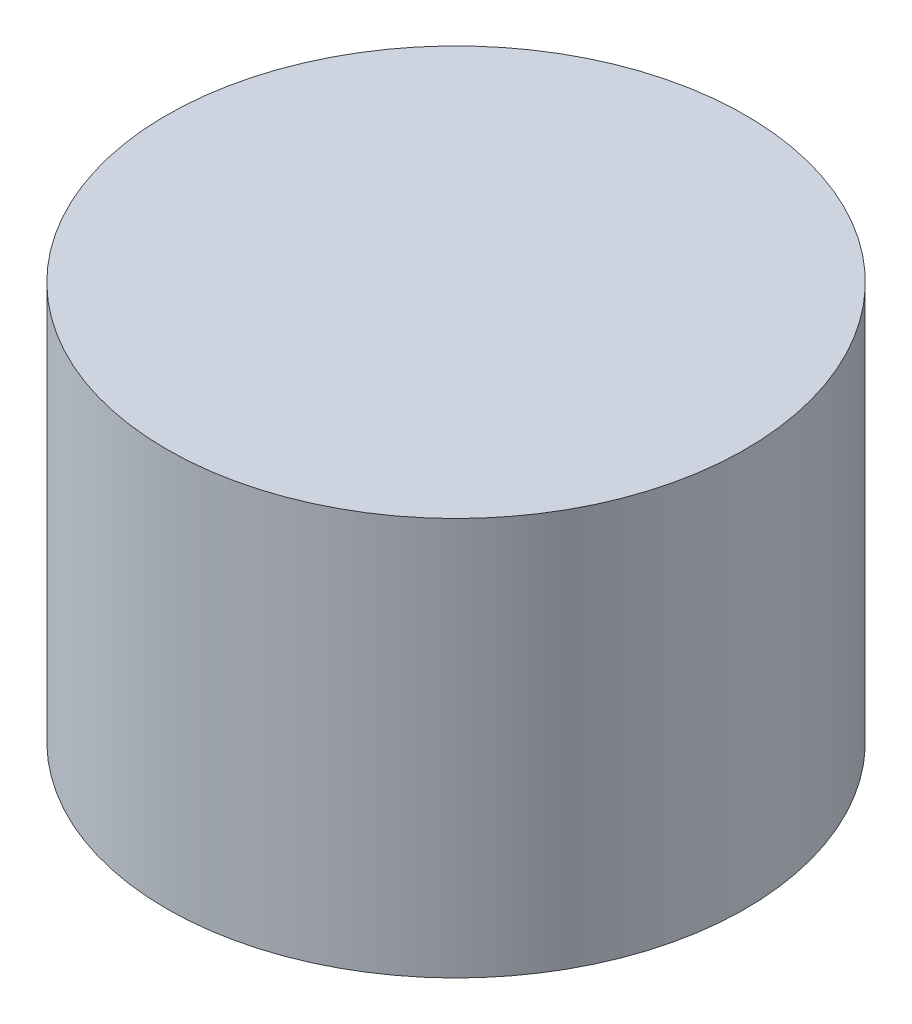
from build123d import *

# Parameters (mm, degrees)
SKETCH1_R           = 4
BOSS_EXTRUDE1_DEPTH = 5.5


with BuildPart() as part:
    # Sketch1 → Boss-Extrude1 (new body)
    with BuildSketch(Plane(origin=(0, 0, 0), x_dir=(1, 0, 0), z_dir=(0, 1, 0))):
        Circle(SKETCH1_R)
    extrude(amount=-BOSS_EXTRUDE1_DEPTH)


solid = part.part
